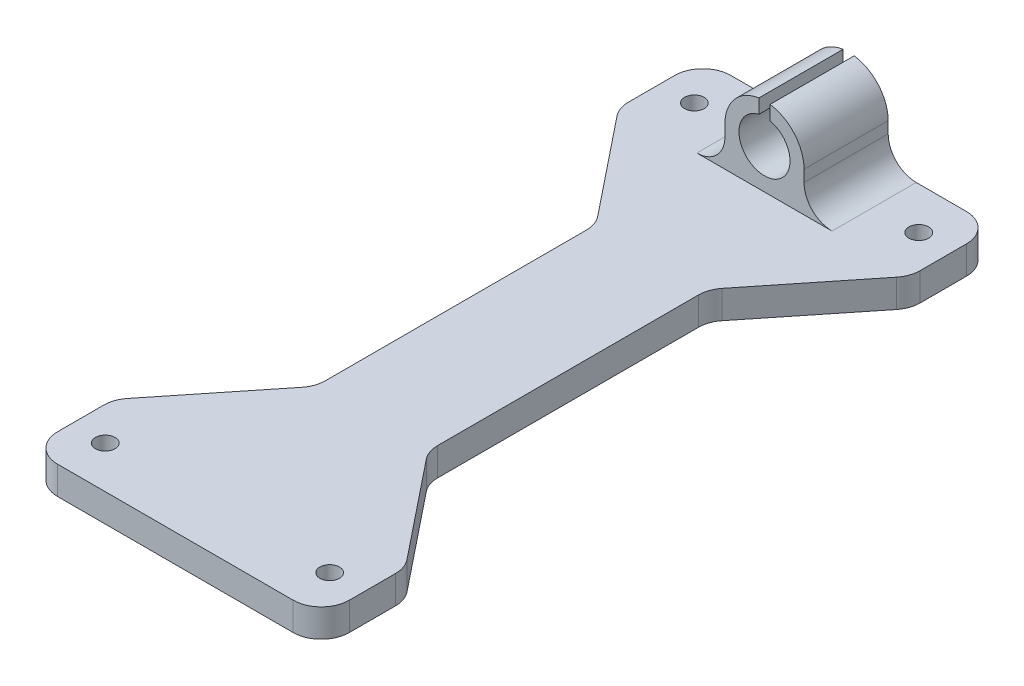
from build123d import *

# Parameters (mm, degrees)
SKETCH2_W           = 52
SKETCH2_H           = 120
SKETCH2_R           = 1.75
BOSS_EXTRUDE1_DEPTH = 5
CUT_EXTRUDE1_DEPTH  = 6
SKETCH4_R           = 4.55
BOSS_EXTRUDE2_DEPTH = 15
SKETCH5_W           = 2
SKETCH5_H           = 2.611250176
CUT_EXTRUDE2_DEPTH  = 121
FILLET1_R           = 5


with BuildPart() as part:
    # Sketch2 → Boss-Extrude1 (new body)
    with BuildSketch(Plane(origin=(0, 0, 0), x_dir=(1, 0, 0), z_dir=(0, 1, 0))):
        with Locations((26, 60)):
            Rectangle(SKETCH2_W, SKETCH2_H)
        with Locations((6, 7.5)):
            Circle(SKETCH2_R, mode=Mode.SUBTRACT)
        with Locations((46, 7.5)):
            Circle(SKETCH2_R, mode=Mode.SUBTRACT)
        with Locations((6, 112.5)):
            Circle(SKETCH2_R, mode=Mode.SUBTRACT)
        with Locations((46, 112.5)):
            Circle(SKETCH2_R, mode=Mode.SUBTRACT)
    extrude(amount=BOSS_EXTRUDE1_DEPTH)

    # Sketch3 → Cut-Extrude1 (cut, through all)
    with BuildSketch(Plane(origin=(0, 5, 0), x_dir=(1, 0, 0), z_dir=(0, 1, 0))):
        Polygon((0, 105), (16, 85), (16, 35), (0, 15), align=None)
        Polygon((52, 105), (36, 85), (36, 35), (52, 15), align=None)
    extrude(amount=-CUT_EXTRUDE1_DEPTH, mode=Mode.SUBTRACT)

    # Sketch4 → Boss-Extrude2 (add)
    with BuildSketch(Plane(origin=(0, 0, -120), x_dir=(-1, 0, 0), z_dir=(0, 0, -1))):
        with BuildLine():
            Line((-33.05, 12.05), (-33.05, 5))
            Line((-33.05, 5), (-18.95, 5))
            Line((-18.95, 5), (-18.95, 12.05))
            ThreePointArc((-18.95, 12.05), (-26, 19.1), (-33.05, 12.05))
        make_face()
        with Locations((-26, 12.05)):
            Circle(SKETCH4_R, mode=Mode.SUBTRACT)
    extrude(amount=-BOSS_EXTRUDE2_DEPTH)

    # Sketch5 → Cut-Extrude2 (cut, through all)
    with BuildSketch(Plane(origin=(0, 0, -120), x_dir=(-1, 0, 0), z_dir=(0, 0, -1))):
        with Locations((-26, 17.794374912)):
            Rectangle(SKETCH5_W, SKETCH5_H)
    extrude(amount=-CUT_EXTRUDE2_DEPTH, mode=Mode.SUBTRACT)

    # Fillet1
    fillet1_edges = [part.edges().sort_by_distance(p)[0] for p in [
        (0, 2.5, -15),
        (0, 2.5, -105),
        (16, 2.5, -85),
        (16, 2.5, -35),
        (52, 2.5, -105),
        (52, 2.5, -15),
        (36, 2.5, -35),
        (36, 2.5, -85),
        (18.95, 5, -112.5),
        (33.05, 5, -112.5),
        (0, 2.5, -120),
        (52, 2.5, -120),
        (52, 2.5, 0),
        (0, 2.5, 0),
    ]]
    fillet(fillet1_edges, radius=FILLET1_R)


solid = part.part
